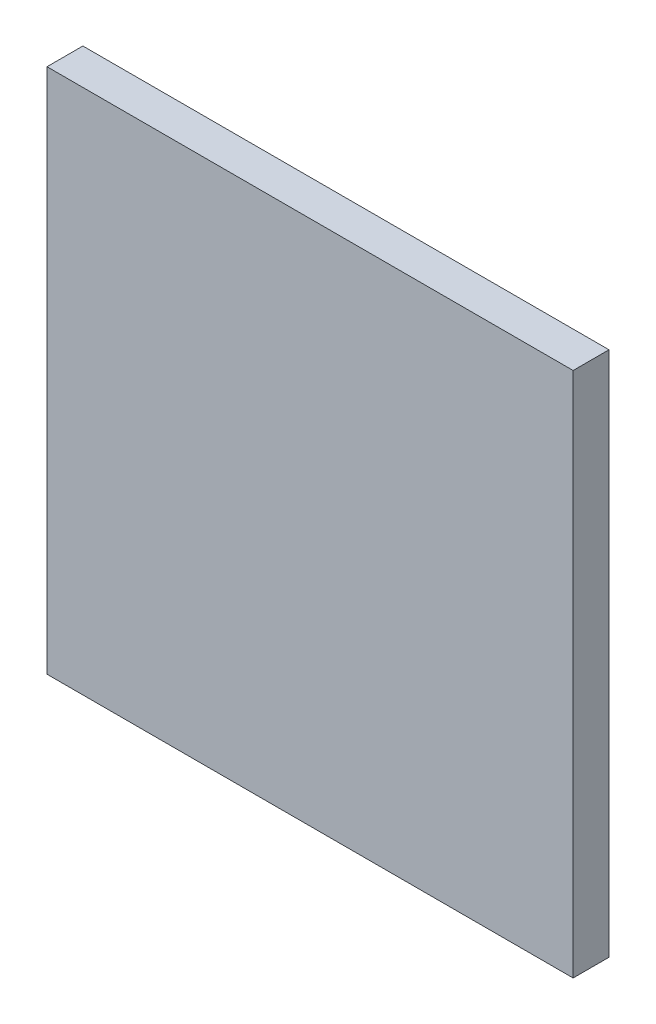
from build123d import *

# Parameters (mm, degrees)
SKETCH1_W            = 279.4
SKETCH1_H            = 279.4
BOSS_EXTRUDE1_DEPTH  = 19.05
SKETCH4_R            = 3.175
CUT_EXTRUDE8_DEPTH   = 12.7
LPATTERN1_COUNT      = 6
LPATTERN1_PITCH      = 50.8
LPATTERN1_COUNT_DIR2 = 6
LPATTERN1_PITCH_DIR2 = 50.8


with BuildPart() as part:
    # Sketch1 → Boss-Extrude1 (new body)
    with BuildSketch(Plane.XY):
        with Locations((139.7, 139.7)):
            Rectangle(SKETCH1_W, SKETCH1_H)
    extrude(amount=BOSS_EXTRUDE1_DEPTH)

    # Sketch4 → Cut-Extrude8 (cut)
    with BuildSketch(Plane(origin=(0, 0, 0), x_dir=(-1, 0, 0), z_dir=(0, 0, -1))):
        with Locations((-9.525, 9.525)):
            Circle(SKETCH4_R)
    cut_extrude8 = extrude(amount=-CUT_EXTRUDE8_DEPTH, mode=Mode.SUBTRACT)

    # LPattern1: Cut-Extrude8 6 × 6
    with Locations(*[(j * LPATTERN1_PITCH_DIR2, i * LPATTERN1_PITCH, 0) for i in range(LPATTERN1_COUNT) for j in range(LPATTERN1_COUNT_DIR2) if (i, j) != (0, 0)]):
        add(cut_extrude8, mode=Mode.SUBTRACT)


solid = part.part
